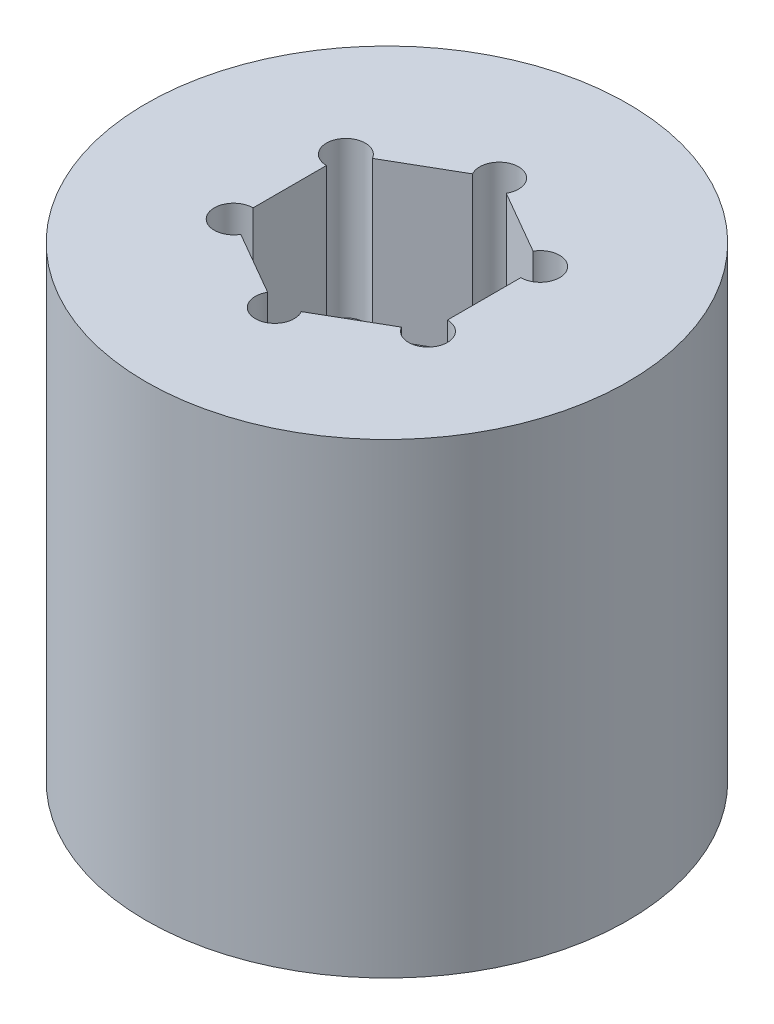
from build123d import *

# Parameters (mm, degrees)
SKETCH3_R           = 19.685
BOSS_EXTRUDE1_DEPTH = 19.05
SKETCH4_R           = 1.5875
SKETCH4_W           = 25.4
SKETCH4_H           = 25.4
CUT_EXTRUDE1_DEPTH  = 19.05
SKETCH5_R           = 1.5875
CUT_EXTRUDE2_DEPTH  = 12.7


with BuildPart() as part:
    # Sketch3 → Boss-Extrude1 (new body, symmetric)
    with BuildSketch(Plane(origin=(0, 0, 0), x_dir=(1, 0, 0), z_dir=(0, 1, 0))):
        Circle(SKETCH3_R)
    extrude(amount=BOSS_EXTRUDE1_DEPTH, both=True)

    # Sketch4 → Cut-Extrude1 (cut)
    with BuildSketch(Plane.XZ.offset(19.05)):
        with Locations((12.7, -12.7)):
            Circle(SKETCH4_R)
        with Locations((-12.7, -12.7)):
            Circle(SKETCH4_R)
        with Locations((-12.7, 12.7)):
            Circle(SKETCH4_R)
        with Locations((12.7, 12.7)):
            Circle(SKETCH4_R)
        Rectangle(SKETCH4_W, SKETCH4_H)
    extrude(amount=-CUT_EXTRUDE1_DEPTH, mode=Mode.SUBTRACT)

    # Sketch5 → Cut-Extrude2 (cut)
    with BuildSketch(Plane(origin=(0, 19.05, 0), x_dir=(1, 0, 0), z_dir=(0, 1, 0))):
        with Locations((7.9375, 4.582717762)):
            Circle(SKETCH5_R)
        with Locations((0, 9.165435523)):
            Circle(SKETCH5_R)
        with Locations((-7.9375, 4.582717762)):
            Circle(SKETCH5_R)
        with Locations((-7.9375, -4.582717762)):
            Circle(SKETCH5_R)
        with Locations((0, -9.165435523)):
            Circle(SKETCH5_R)
        with Locations((7.9375, -4.582717762)):
            Circle(SKETCH5_R)
        Polygon((7.9375, 4.582717762), (0, 9.165435523), (-7.9375, 4.582717762), (-7.9375, -4.582717762), (0, -9.165435523), (7.9375, -4.582717762), align=None)
        with BuildLine():
            ThreePointArc((-6.35, -4.582717762), (-6.814967985, -3.460185747), (-7.9375, -2.995217762))
            Line((-7.9375, -2.995217762), (-7.9375, -4.582717762))
            Line((-7.9375, -4.582717762), (-6.562684671, -5.376467762))
            ThreePointArc((-6.562684671, -5.376467762), (-6.404092751, -4.993592996), (-6.35, -4.582717762))
        make_face()
        with BuildLine():
            Line((-7.9375, -4.582717762), (-7.9375, -2.995217762))
            ThreePointArc((-7.9375, -2.995217762), (-9.312315329, -5.376467762), (-6.562684671, -5.376467762))
            Line((-6.562684671, -5.376467762), (-7.9375, -4.582717762))
        make_face()
        with BuildLine():
            ThreePointArc((1.374815329, -8.371685523), (0, -7.577935523), (-1.374815329, -8.371685523))
            Line((-1.374815329, -8.371685523), (0, -9.165435523))
            Line((0, -9.165435523), (1.374815329, -8.371685523))
        make_face()
        with BuildLine():
            Line((0, -9.165435523), (-1.374815329, -8.371685523))
            ThreePointArc((-1.374815329, -8.371685523), (-0.410875234, -10.698842773), (1.5875, -9.165435523))
            ThreePointArc((1.5875, -9.165435523), (1.533407249, -8.754560289), (1.374815329, -8.371685523))
            Line((1.374815329, -8.371685523), (0, -9.165435523))
        make_face()
        with BuildLine():
            ThreePointArc((9.525, -4.582717762), (9.060032015, -3.460185747), (7.9375, -2.995217762))
            Line((7.9375, -2.995217762), (7.9375, -4.582717762))
            Line((7.9375, -4.582717762), (6.562684671, -5.376467762))
            ThreePointArc((6.562684671, -5.376467762), (8.348375234, -6.116125011), (9.525, -4.582717762))
        make_face()
        with BuildLine():
            Line((7.9375, -4.582717762), (7.9375, -2.995217762))
            ThreePointArc((7.9375, -2.995217762), (6.562684671, -3.788967762), (6.562684671, -5.376467762))
            Line((6.562684671, -5.376467762), (7.9375, -4.582717762))
        make_face()
        with BuildLine():
            ThreePointArc((9.525, 4.582717762), (8.348375234, 6.116125011), (6.562684671, 5.376467762))
            Line((6.562684671, 5.376467762), (7.9375, 4.582717762))
            Line((7.9375, 4.582717762), (7.9375, 2.995217762))
            ThreePointArc((7.9375, 2.995217762), (9.060032015, 3.460185747), (9.525, 4.582717762))
        make_face()
        with BuildLine():
            Line((7.9375, 4.582717762), (6.562684671, 5.376467762))
            ThreePointArc((6.562684671, 5.376467762), (6.562684671, 3.788967762), (7.9375, 2.995217762))
            Line((7.9375, 2.995217762), (7.9375, 4.582717762))
        make_face()
        with BuildLine():
            Line((1.374815329, 8.371685523), (0, 9.165435523))
            Line((0, 9.165435523), (-1.374815329, 8.371685523))
            ThreePointArc((-1.374815329, 8.371685523), (0, 7.577935523), (1.374815329, 8.371685523))
        make_face()
        with BuildLine():
            Line((-1.374815329, 8.371685523), (0, 9.165435523))
            Line((0, 9.165435523), (1.374815329, 8.371685523))
            ThreePointArc((1.374815329, 8.371685523), (1.533407249, 8.754560289), (1.5875, 9.165435523))
            ThreePointArc((1.5875, 9.165435523), (-0.410875234, 10.698842773), (-1.374815329, 8.371685523))
        make_face()
        with BuildLine():
            ThreePointArc((-6.35, 4.582717762), (-6.404092751, 4.993592996), (-6.562684671, 5.376467762))
            Line((-6.562684671, 5.376467762), (-7.9375, 4.582717762))
            Line((-7.9375, 4.582717762), (-7.9375, 2.995217762))
            ThreePointArc((-7.9375, 2.995217762), (-6.814967985, 3.460185747), (-6.35, 4.582717762))
        make_face()
        with BuildLine():
            Line((-7.9375, 4.582717762), (-6.562684671, 5.376467762))
            ThreePointArc((-6.562684671, 5.376467762), (-9.312315329, 5.376467762), (-7.9375, 2.995217762))
            Line((-7.9375, 2.995217762), (-7.9375, 4.582717762))
        make_face()
    extrude(amount=-CUT_EXTRUDE2_DEPTH, mode=Mode.SUBTRACT)


solid = part.part
